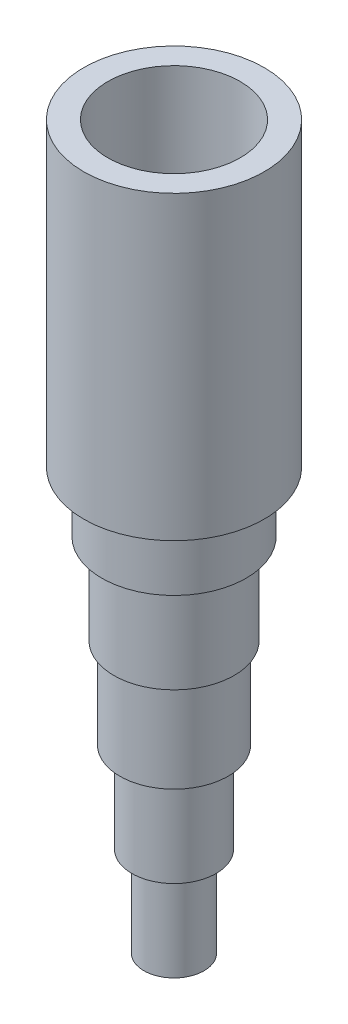
from build123d import *

# Parameters (mm, degrees)
SKETCH1_W = 3.175
SKETCH1_H = 9.525
SHELL1_T  = -2.54


with BuildPart() as part:
    # Sketch1 → Revolve5 (revolve)
    with BuildSketch(Plane.XY, mode=Mode.PRIVATE) as revolve5_sk:
        Polygon((49.470878753, 15.571822686), (49.470878753, 47.321822686), (39.945878753, 47.321822686), (39.945878753, 15.571822686), (41.850878753, 15.571822686), align=None)
        Polygon((49.470878753, 9.221822686), (49.470878753, 15.571822686), (41.850878753, 15.571822686), (41.850878753, 9.221822686), (43.120878753, 9.221822686), align=None)
        Polygon((49.470878753, -0.303177314), (49.470878753, 9.221822686), (43.120878753, 9.221822686), (43.120878753, -0.303177314), (43.755878753, -0.303177314), align=None)
        Polygon((49.470878753, -9.828177314), (49.470878753, -0.303177314), (43.755878753, -0.303177314), (43.755878753, -9.828177314), (45.025878753, -9.828177314), align=None)
        Polygon((49.470878753, -19.353177314), (49.470878753, -9.828177314), (45.025878753, -9.828177314), (45.025878753, -19.353177314), (46.295878753, -19.353177314), align=None)
        with Locations((47.883378753, -24.115677314)):
            Rectangle(SKETCH1_W, SKETCH1_H)
    revolve(revolve5_sk.sketch.rotate(Axis((49.470878753, -38.227970454, 0), (0, 1, 0)), 270), axis=Axis((49.470878753, -38.227970454, 0), (0, 1, 0)))

    # Shell1
    shell1_openings = [part.faces().sort_by_distance(p)[0] for p in [
        (49.470878753, 47.321822686, 0),
        (49.470878753, -28.878177314, 0),
    ]]
    offset(amount=SHELL1_T, openings=shell1_openings, kind=Kind.INTERSECTION)


solid = part.part
